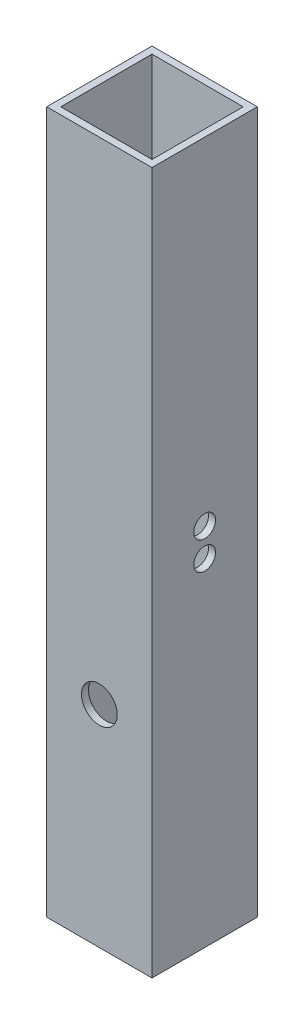
from build123d import *

# Parameters (mm, degrees)
SKETCH_1_W          = 15
SKETCH_1_H          = 15
SKETCH_1_W_2        = 13
SKETCH_1_H_2        = 13
EXTRUDE_1_DEPTH     = 100
SKETCH_2_R          = 2.55
CUT_EXTRUDE_1_DEPTH = 100
SKETCH_4_R          = 1.55
CUT_EXTRUDE_2_DEPTH = 15


with BuildPart() as part:
    # 草图1 → 凸台-拉伸1 (new body)
    with BuildSketch(Plane(origin=(0, 0, 0), x_dir=(1, 0, 0), z_dir=(0, 1, 0))):
        Rectangle(SKETCH_1_W, SKETCH_1_H)
        Rectangle(SKETCH_1_W_2, SKETCH_1_H_2, mode=Mode.SUBTRACT)
    extrude(amount=EXTRUDE_1_DEPTH)

    # 草图2 → 切除-拉伸1 (cut)
    with BuildSketch(Plane.XY.offset(7.5)):
        with Locations((0, 30)):
            Circle(SKETCH_2_R)
    extrude(amount=-CUT_EXTRUDE_1_DEPTH, mode=Mode.SUBTRACT)

    # 草图4 → 切除-拉伸2 (cut)
    with BuildSketch(Plane(origin=(7.5, 0, 0), x_dir=(0, 0, -1), z_dir=(1, 0, 0))):
        with Locations((0, 52)):
            Circle(SKETCH_4_R)
        with Locations((0, 48)):
            Circle(SKETCH_4_R)
    extrude(amount=-CUT_EXTRUDE_2_DEPTH, mode=Mode.SUBTRACT)


solid = part.part
